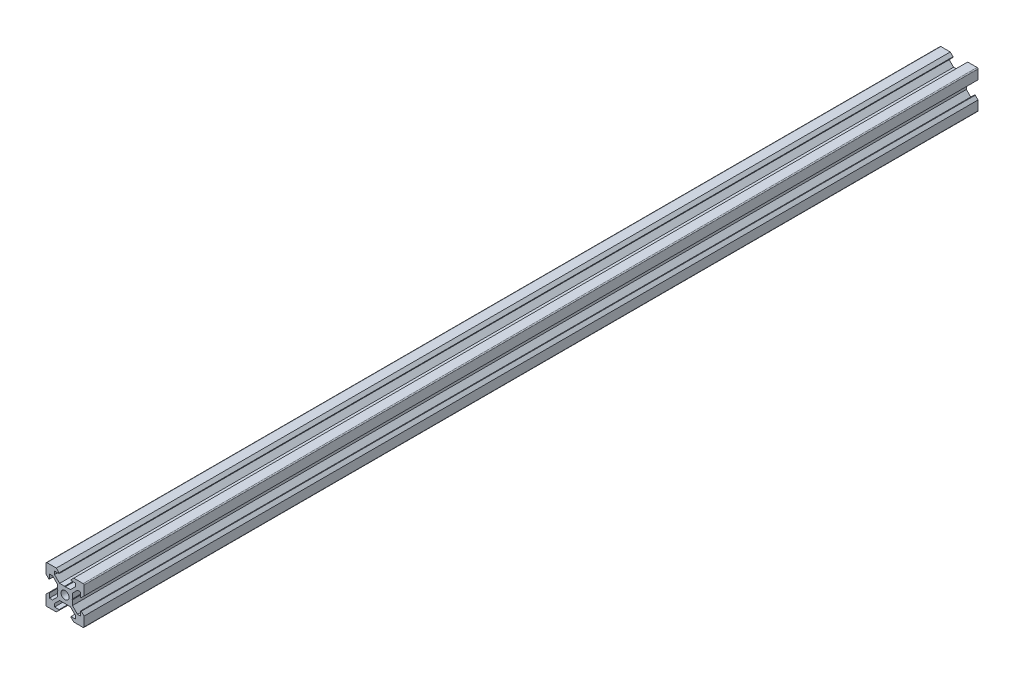
from build123d import *

# Parameters (mm, degrees)
SKETCH1_R           = 2.1
BOSS_EXTRUDE1_DEPTH = 235


with BuildPart() as part:
    # Sketch1 → Boss-Extrude1 (new body, symmetric)
    with BuildSketch(Plane.XY):
        with BuildLine():
            Line((4.58, -10), (9.5, -10))
            ThreePointArc((9.5, -10), (9.853553391, -9.853553391), (10, -9.5))
            Line((10, -9.5), (10, -4.58))
            Line((10, -4.58), (8.545, -3.125))
            Line((8.545, -3.125), (8.2, -3.125))
            Line((8.2, -3.125), (8.2, -5.5))
            Line((8.2, -5.5), (6.560660172, -5.5))
            Line((6.560660172, -5.5), (3.9, -2.839339828))
            Line((3.9, -2.839339828), (3.9, -0.21))
            Line((3.9, -0.21), (3.69, 0))
            Line((3.69, 0), (3.9, 0.21))
            Line((3.9, 0.21), (3.9, 2.839339828))
            Line((3.9, 2.839339828), (6.560660172, 5.5))
            Line((6.560660172, 5.5), (8.2, 5.5))
            Line((8.2, 5.5), (8.2, 3.125))
            Line((8.2, 3.125), (8.545, 3.125))
            Line((8.545, 3.125), (10, 4.58))
            Line((10, 4.58), (10, 9.5))
            ThreePointArc((10, 9.5), (9.853553391, 9.853553391), (9.5, 10))
            Line((9.5, 10), (4.58, 10))
            Line((4.58, 10), (3.125, 8.545))
            Line((3.125, 8.545), (3.125, 8.2))
            Line((3.125, 8.2), (5.5, 8.2))
            Line((5.5, 8.2), (5.5, 6.560660172))
            Line((5.5, 6.560660172), (2.839339828, 3.9))
            Line((2.839339828, 3.9), (0.21, 3.9))
            Line((0.21, 3.9), (0, 3.69))
            Line((0, 3.69), (-0.21, 3.9))
            Line((-0.21, 3.9), (-2.839339828, 3.9))
            Line((-2.839339828, 3.9), (-5.5, 6.560660172))
            Line((-5.5, 6.560660172), (-5.5, 8.2))
            Line((-5.5, 8.2), (-3.125, 8.2))
            Line((-3.125, 8.2), (-3.125, 8.545))
            Line((-3.125, 8.545), (-4.58, 10))
            Line((-4.58, 10), (-9.5, 10))
            ThreePointArc((-9.5, 10), (-9.853553391, 9.853553391), (-10, 9.5))
            Line((-10, 9.5), (-10, 4.58))
            Line((-10, 4.58), (-8.545, 3.125))
            Line((-8.545, 3.125), (-8.2, 3.125))
            Line((-8.2, 3.125), (-8.2, 5.5))
            Line((-8.2, 5.5), (-6.560660172, 5.5))
            Line((-6.560660172, 5.5), (-3.9, 2.839339828))
            Line((-3.9, 2.839339828), (-3.9, 0.21))
            Line((-3.9, 0.21), (-3.69, 0))
            Line((-3.69, 0), (-3.9, -0.21))
            Line((-3.9, -0.21), (-3.9, -2.839339828))
            Line((-3.9, -2.839339828), (-6.560660172, -5.5))
            Line((-6.560660172, -5.5), (-8.2, -5.5))
            Line((-8.2, -5.5), (-8.2, -3.125))
            Line((-8.2, -3.125), (-8.545, -3.125))
            Line((-8.545, -3.125), (-10, -4.58))
            Line((-10, -4.58), (-10, -9.5))
            ThreePointArc((-10, -9.5), (-9.853553391, -9.853553391), (-9.5, -10))
            Line((-9.5, -10), (-4.58, -10))
            Line((-4.58, -10), (-3.125, -8.545))
            Line((-3.125, -8.545), (-3.125, -8.2))
            Line((-3.125, -8.2), (-5.5, -8.2))
            Line((-5.5, -8.2), (-5.5, -6.560660172))
            Line((-5.5, -6.560660172), (-2.839339828, -3.9))
            Line((-2.839339828, -3.9), (-0.21, -3.9))
            Line((-0.21, -3.9), (0, -3.69))
            Line((0, -3.69), (0.21, -3.9))
            Line((0.21, -3.9), (2.839339828, -3.9))
            Line((2.839339828, -3.9), (5.5, -6.560660172))
            Line((5.5, -6.560660172), (5.5, -8.2))
            Line((5.5, -8.2), (3.125, -8.2))
            Line((3.125, -8.2), (3.125, -8.545))
            Line((3.125, -8.545), (4.58, -10))
        make_face()
        Circle(SKETCH1_R, mode=Mode.SUBTRACT)
    extrude(amount=BOSS_EXTRUDE1_DEPTH, both=True)


solid = part.part
